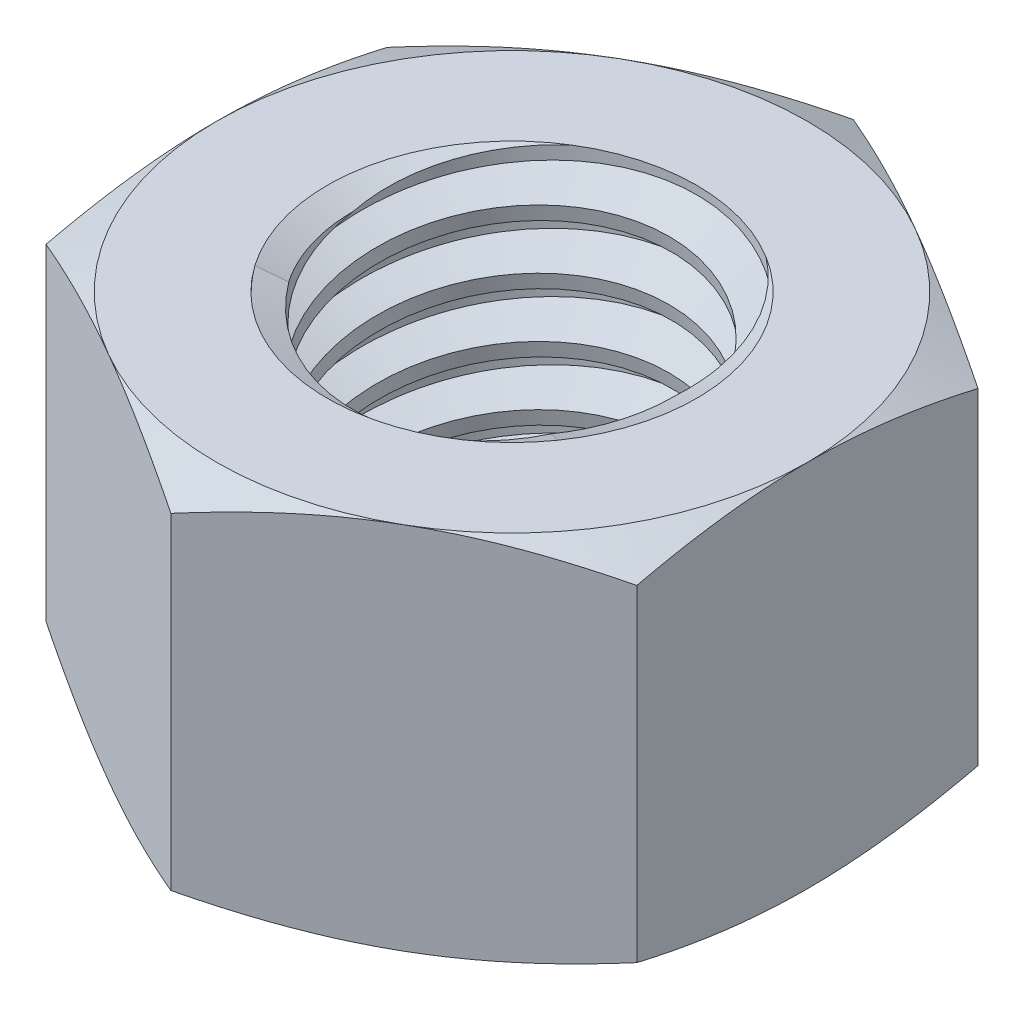
from build123d import *

# Parameters (mm, degrees)
EXTRUDE1_DEPTH      = 2.5
SKETCH2_W           = 2.5
SKETCH2_H           = 5
LPATTERN1_COUNT     = 6
LPATTERN1_PITCH     = 0.8
LPATTERN1_COL_COUNT = 2
LPATTERN1_COL_PITCH = 0.8


with BuildPart() as part:
    # Sketch1 → Extrude1 (new body, symmetric)
    with BuildSketch(Plane(origin=(0, 0, 0), x_dir=(1, 0, 0), z_dir=(0, 1, 0))):
        Polygon((0, 4.618802154), (-4, 2.309401077), (-4, -2.309401077), (0, -4.618802154), (4, -2.309401077), (4, 2.309401077), align=None)
    extrude(amount=EXTRUDE1_DEPTH, both=True)

    # Sketch4 → Cut-Revolve2 (revolve, cut)
    with BuildSketch(Plane(origin=(0, 0, 0), x_dir=(0, 0, -1), z_dir=(1, 0, 0))):
        Polygon((0, 2.5), (2.5, 2.5), (2.127722339, 2.326404076), (2.127722339, -2.326404076), (2.5, -2.5), (0, -2.5), align=None)
    revolve(axis=Axis((0, 2.5, 0), (0, 1, 0)), mode=Mode.SUBTRACT)


with BuildPart() as body_2:
    # Sketch2 → Revolve1 (revolve)
    with BuildSketch(Plane(origin=(0, 0, 0), x_dir=(0, 0, -1), z_dir=(1, 0, 0))):
        with Locations((1.25, 0)):
            Rectangle(SKETCH2_W, SKETCH2_H)
    revolve(axis=Axis((0, -5, 0), (0, 1, 0)))

    # Sketch3 → Cut-Revolve1 (revolve, cut)
    with BuildSketch(Plane(origin=(0, 0, 0), x_dir=(0, 0, -1), z_dir=(1, 0, 0))):
        Polygon((2.51579905, 2.401255937), (2.626392401, 1.710047494), (2.15932044, 1.888495759), (2.127722339, 2.085983885), align=None)
    cut_revolve1 = revolve(axis=Axis((0, 2.5, 0.136915776), (0, -0.987440632, -0.157990501)), mode=Mode.SUBTRACT)

    # LPattern1: Cut-Revolve1 ×6
    with Locations(*[(0, -i * LPATTERN1_PITCH, 0) for i in range(1, LPATTERN1_COUNT)]):
        add(cut_revolve1, mode=Mode.SUBTRACT)

    # LPattern1 col: Cut-Revolve1 ×2
    with Locations(*[(0, i * LPATTERN1_COL_PITCH, 0) for i in range(1, LPATTERN1_COL_COUNT)]):
        add(cut_revolve1, mode=Mode.SUBTRACT)


with BuildPart() as part_1:
    add(part.part)

    # Combine1: cut body 2
    add(body_2.part, mode=Mode.SUBTRACT)

    # Sketch5 → Cut-Revolve3 (revolve, cut)
    with BuildSketch(Plane(origin=(0, 0, 0), x_dir=(0, 0, -1), z_dir=(1, 0, 0))):
        Polygon((0, -2.5), (4, -2.5), (4.618802154, -2.211447817), (4.618802154, 2.211447817), (4, 2.5), (0, 2.5), (0, 3.77), (5.888802154, 3.77), (5.888802154, -3.77), (0, -3.77), align=None)
    revolve(axis=Axis((0, -2.5, 0), (0, 1, 0)), mode=Mode.SUBTRACT)


solid = part_1.part
